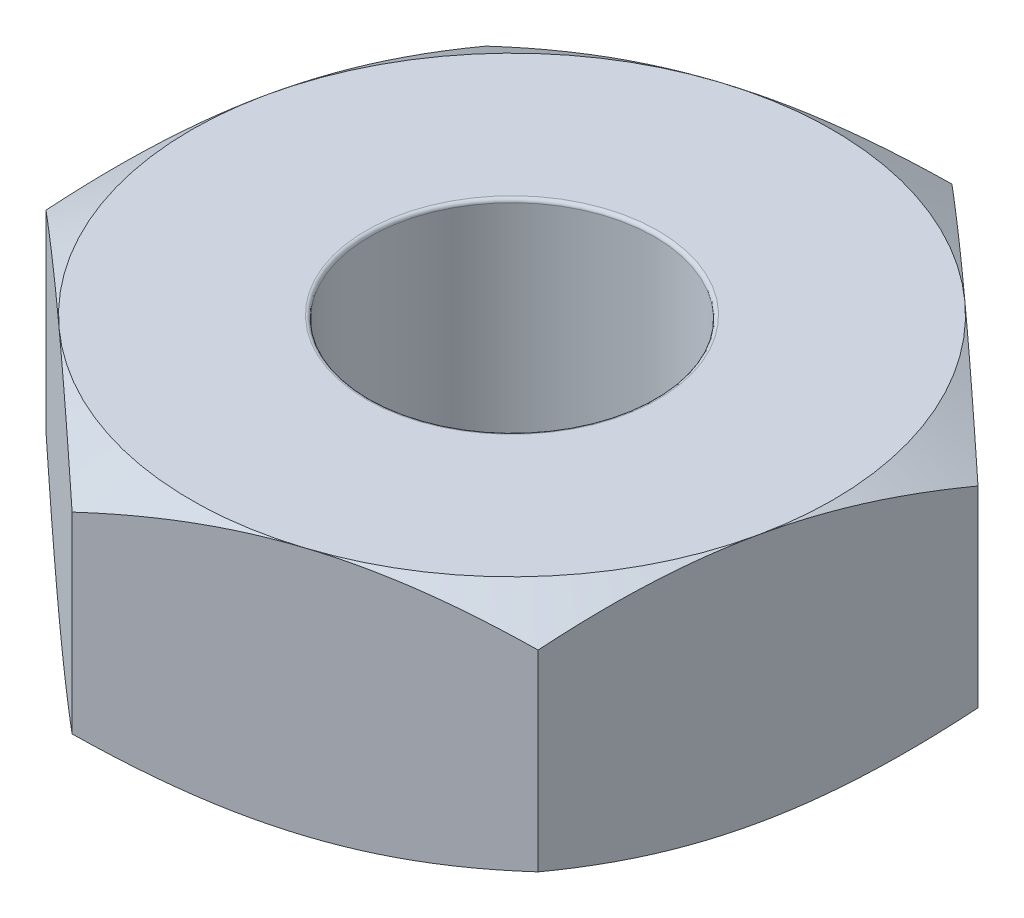
from build123d import *

# Parameters (mm, degrees)
SKETCH1_R           = 1
BOSS_EXTRUDE1_DEPTH = 1.75
SKETCH2_OUTSIDE_W   = 14.468
SKETCH2_OUTSIDE_H   = 14.602
SKETCH2_OUTSIDE_R   = 2.25
CUT_EXTRUDE1_DEPTH  = 1.75
CUT_EXTRUDE1_TAPER  = 60
SKETCH3_OUTSIDE_W   = 14.468
SKETCH3_OUTSIDE_H   = 14.602
SKETCH3_OUTSIDE_R   = 2.25
CUT_EXTRUDE2_DEPTH  = 1.75
CUT_EXTRUDE2_TAPER  = 60
FILLET1_R           = 0.025


with BuildPart() as part:
    # Sketch1 → Boss-Extrude1 (new body)
    with BuildSketch(Plane(origin=(0, 0, 0), x_dir=(1, 0, 0), z_dir=(0, 1, 0))):
        Polygon((-2.472933755, -0.796617), (-0.546576318, -2.539931953), (1.926357436, -1.743314953), (2.472933755, 0.796617), (0.546576318, 2.539931953), (-1.926357436, 1.743314953), align=None)
        Circle(SKETCH1_R, mode=Mode.SUBTRACT)
    extrude(amount=BOSS_EXTRUDE1_DEPTH)

    # Sketch2 outside → Cut-Extrude1 (cut)
    with BuildSketch(Plane(origin=(0, 1.75, 0), x_dir=(1, 0, 0), z_dir=(0, 1, 0))):
        Rectangle(SKETCH2_OUTSIDE_W, SKETCH2_OUTSIDE_H)
        Circle(SKETCH2_OUTSIDE_R, mode=Mode.SUBTRACT)
    extrude(amount=-CUT_EXTRUDE1_DEPTH, taper=CUT_EXTRUDE1_TAPER, mode=Mode.SUBTRACT)

    # Sketch3 outside → Cut-Extrude2 (cut)
    with BuildSketch(Plane.XZ):
        Rectangle(SKETCH3_OUTSIDE_W, SKETCH3_OUTSIDE_H)
        Circle(SKETCH3_OUTSIDE_R, mode=Mode.SUBTRACT)
    extrude(amount=-CUT_EXTRUDE2_DEPTH, taper=CUT_EXTRUDE2_TAPER, mode=Mode.SUBTRACT)

    # Fillet1
    fillet1_edges = [part.edges().sort_by_distance(p)[0] for p in [
        (-1, 0, 0),
        (-1, 1.75, 0),
    ]]
    fillet(fillet1_edges, radius=FILLET1_R)


solid = part.part
